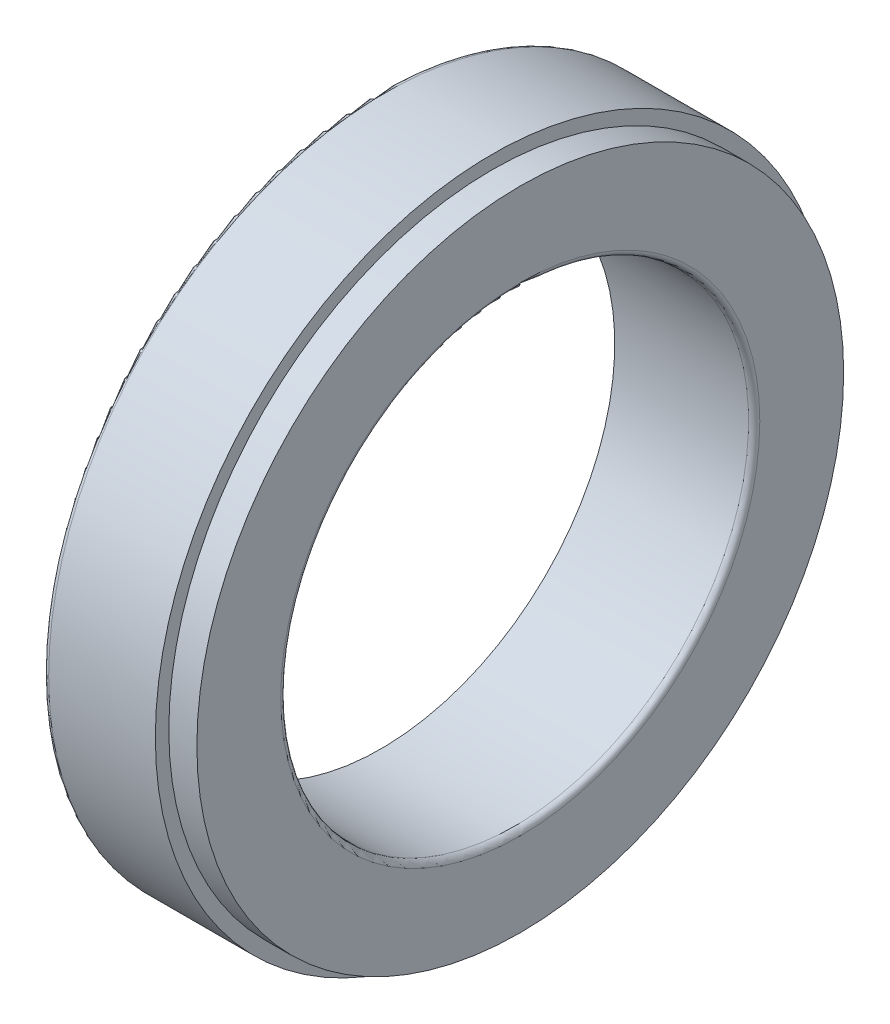
from build123d import *


with BuildPart() as part:
    # Эскиз1 → Повернуть1 (revolve)
    with BuildSketch(Plane.XY):
        with BuildLine():
            Line((0.6, 36), (12, 36))
            Line((12, 36), (12, 34.561))
            Line((12, 34.561), (15, 34.561))
            Line((15, 34.561), (15, 25.6))
            ThreePointArc((15, 25.6), (14.824264069, 25.175735931), (14.4, 25))
            Line((14.4, 25), (0.1, 25))
            Line((0.1, 25), (0.1, 31.374))
            Line((0.1, 31.374), (0, 31.374))
            Line((0, 31.374), (0, 35.4))
            ThreePointArc((0, 35.4), (0.175735931, 35.824264069), (0.6, 36))
        make_face()
    revolve(axis=Axis((-1000, 0, 0), (1, 0, 0)))


solid = part.part
